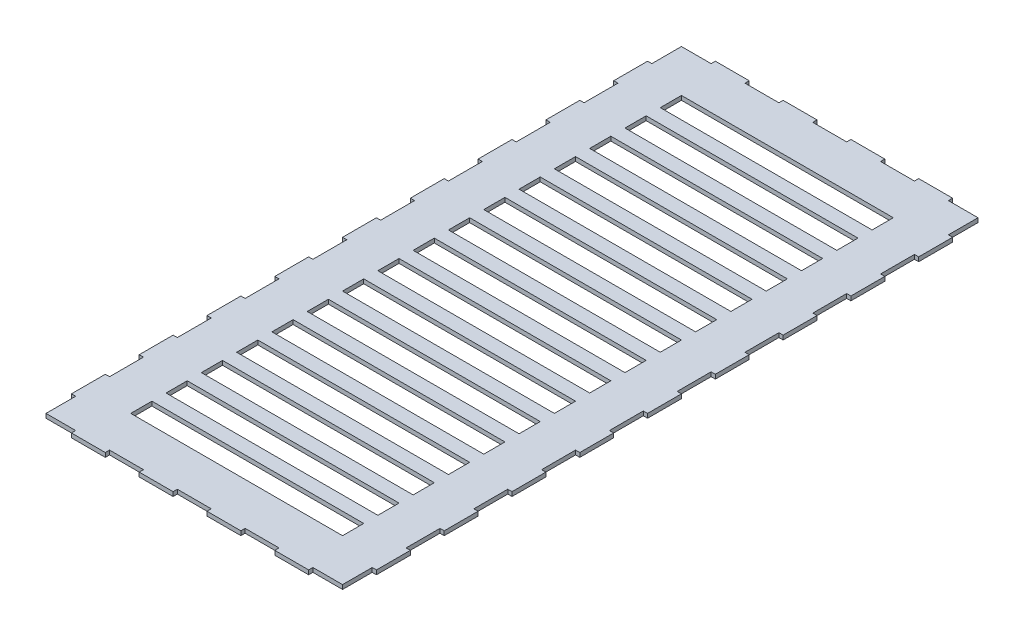
from build123d import *

# Parameters (mm, degrees)
SKETCH1_W           = 210
SKETCH1_H           = 450
SKETCH1_W_2         = 150
SKETCH1_H_2         = 15
BOSS_EXTRUDE1_DEPTH = 3
SKETCH3_W           = 3
SKETCH3_H           = 24
BOSS_EXTRUDE3_DEPTH = 3
SKETCH2_W           = 24
SKETCH2_H           = 3
BOSS_EXTRUDE4_DEPTH = 3


with BuildPart() as part:
    # Sketch1 → Boss-Extrude1 (new body)
    with BuildSketch(Plane(origin=(0, 0, 0), x_dir=(1, 0, 0), z_dir=(0, 1, 0))):
        Rectangle(SKETCH1_W, SKETCH1_H)
        with Locations((0, -162.5)):
            Rectangle(SKETCH1_W_2, SKETCH1_H_2, mode=Mode.SUBTRACT)
        with Locations((0, -187.5)):
            Rectangle(SKETCH1_W_2, SKETCH1_H_2, mode=Mode.SUBTRACT)
        with Locations((0, -137.5)):
            Rectangle(SKETCH1_W_2, SKETCH1_H_2, mode=Mode.SUBTRACT)
        with Locations((0, -112.5)):
            Rectangle(SKETCH1_W_2, SKETCH1_H_2, mode=Mode.SUBTRACT)
        with Locations((0, -87.5)):
            Rectangle(SKETCH1_W_2, SKETCH1_H_2, mode=Mode.SUBTRACT)
        with Locations((0, -62.5)):
            Rectangle(SKETCH1_W_2, SKETCH1_H_2, mode=Mode.SUBTRACT)
        with Locations((0, -37.5)):
            Rectangle(SKETCH1_W_2, SKETCH1_H_2, mode=Mode.SUBTRACT)
        with Locations((0, -12.5)):
            Rectangle(SKETCH1_W_2, SKETCH1_H_2, mode=Mode.SUBTRACT)
        with Locations((0, 12.5)):
            Rectangle(SKETCH1_W_2, SKETCH1_H_2, mode=Mode.SUBTRACT)
        with Locations((0, 37.5)):
            Rectangle(SKETCH1_W_2, SKETCH1_H_2, mode=Mode.SUBTRACT)
        with Locations((0, 62.5)):
            Rectangle(SKETCH1_W_2, SKETCH1_H_2, mode=Mode.SUBTRACT)
        with Locations((0, 87.5)):
            Rectangle(SKETCH1_W_2, SKETCH1_H_2, mode=Mode.SUBTRACT)
        with Locations((0, 112.5)):
            Rectangle(SKETCH1_W_2, SKETCH1_H_2, mode=Mode.SUBTRACT)
        with Locations((0, 137.5)):
            Rectangle(SKETCH1_W_2, SKETCH1_H_2, mode=Mode.SUBTRACT)
        with Locations((0, 162.5)):
            Rectangle(SKETCH1_W_2, SKETCH1_H_2, mode=Mode.SUBTRACT)
        with Locations((0, 187.5)):
            Rectangle(SKETCH1_W_2, SKETCH1_H_2, mode=Mode.SUBTRACT)
    extrude(amount=BOSS_EXTRUDE1_DEPTH)

    # Sketch3 → Boss-Extrude3 (add)
    with BuildSketch(Plane(origin=(0, 3, 0), x_dir=(1, 0, 0), z_dir=(0, 1, 0))):
        with Locations((-106.5, 192)):
            Rectangle(SKETCH3_W, SKETCH3_H)
        with Locations((106.5, 192)):
            Rectangle(SKETCH3_W, SKETCH3_H)
        with Locations((106.5, 144)):
            Rectangle(SKETCH3_W, SKETCH3_H)
        with Locations((106.5, 96)):
            Rectangle(SKETCH3_W, SKETCH3_H)
        with Locations((106.5, 48)):
            Rectangle(SKETCH3_W, SKETCH3_H)
        with Locations((106.5, 0)):
            Rectangle(SKETCH3_W, SKETCH3_H)
        with Locations((106.5, -48)):
            Rectangle(SKETCH3_W, SKETCH3_H)
        with Locations((106.5, -96)):
            Rectangle(SKETCH3_W, SKETCH3_H)
        with Locations((106.5, -144)):
            Rectangle(SKETCH3_W, SKETCH3_H)
        with Locations((106.5, -192)):
            Rectangle(SKETCH3_W, SKETCH3_H)
        with Locations((-106.5, 144)):
            Rectangle(SKETCH3_W, SKETCH3_H)
        with Locations((-106.5, 96)):
            Rectangle(SKETCH3_W, SKETCH3_H)
        with Locations((-106.5, 48)):
            Rectangle(SKETCH3_W, SKETCH3_H)
        with Locations((-106.5, 0)):
            Rectangle(SKETCH3_W, SKETCH3_H)
        with Locations((-106.5, -48)):
            Rectangle(SKETCH3_W, SKETCH3_H)
        with Locations((-106.5, -96)):
            Rectangle(SKETCH3_W, SKETCH3_H)
        with Locations((-106.5, -144)):
            Rectangle(SKETCH3_W, SKETCH3_H)
        with Locations((-106.5, -192)):
            Rectangle(SKETCH3_W, SKETCH3_H)
    extrude(amount=-BOSS_EXTRUDE3_DEPTH)

    # Sketch2 → Boss-Extrude4 (add)
    with BuildSketch(Plane(origin=(0, 3, 0), x_dir=(1, 0, 0), z_dir=(0, 1, 0))):
        with Locations((-72, 226.5)):
            Rectangle(SKETCH2_W, SKETCH2_H)
        with Locations((-24, 226.5)):
            Rectangle(SKETCH2_W, SKETCH2_H)
        with Locations((24, 226.5)):
            Rectangle(SKETCH2_W, SKETCH2_H)
        with Locations((72, 226.5)):
            Rectangle(SKETCH2_W, SKETCH2_H)
        with Locations((-71.999992971, -226.5)):
            Rectangle(SKETCH2_W, SKETCH2_H)
        with Locations((-23.999992971, -226.5)):
            Rectangle(SKETCH2_W, SKETCH2_H)
        with Locations((24.000007029, -226.5)):
            Rectangle(SKETCH2_W, SKETCH2_H)
        with Locations((72.000007029, -226.5)):
            Rectangle(SKETCH2_W, SKETCH2_H)
    extrude(amount=-BOSS_EXTRUDE4_DEPTH)


solid = part.part
